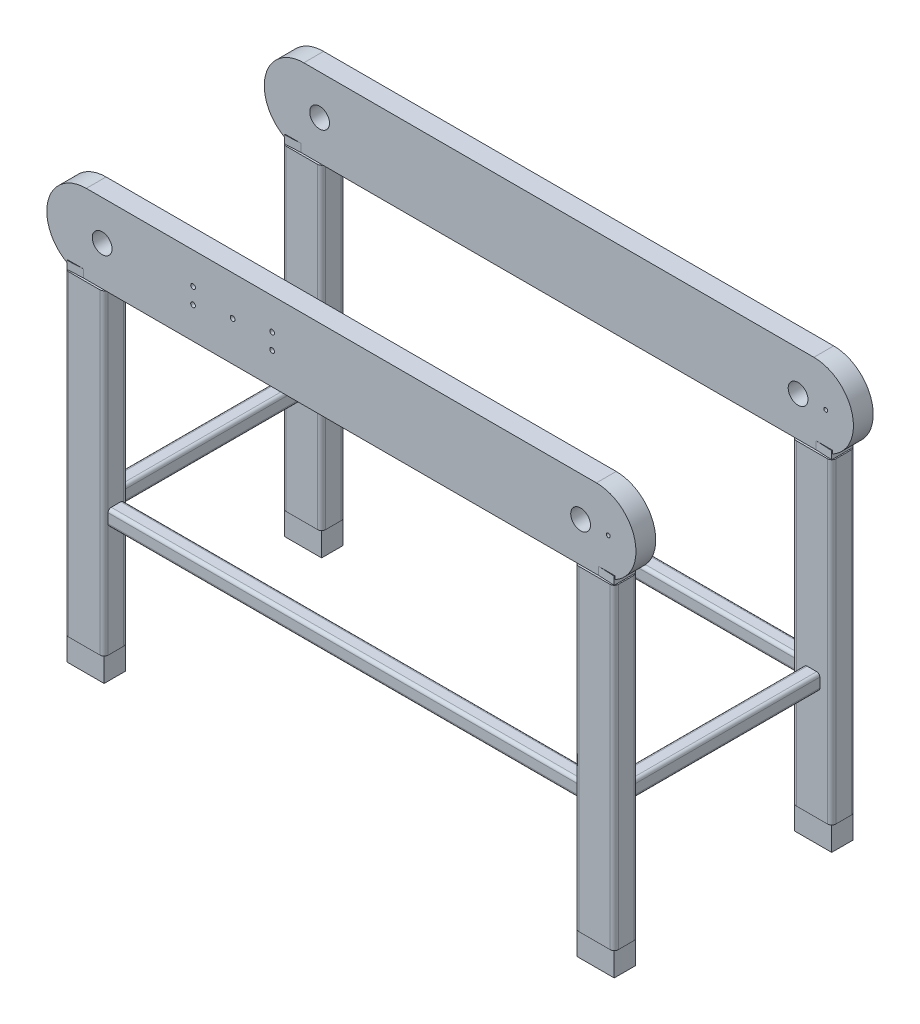
from build123d import *

# Parameters (mm, degrees)
BOSS_EXTRUDE3_START                          = 125
SKETCH4_R                                    = 12.5
BOSS_EXTRUDE3_DEPTH                          = 25
RECTANGULAR_TUBE_CONFIGURED_50_X_30_X_DEPTH  = 400
RECTANGULAR_TUBE_CONFIGURED_50_X_3_2_DEPTH   = 400
RECTANGULAR_TUBE_CONFIGURED_50_X_3_3_DEPTH   = 400
RECTANGULAR_TUBE_CONFIGURED_50_X_3_4_DEPTH   = 400
BOSS_EXTRUDE6_DEPTH                          = 10
LPATTERN2_COUNT                              = 2
LPATTERN2_PITCH                              = 275
BOSS_EXTRUDE7_DEPTH                          = 10
SQUARE_TUBE_CONFIGURED_20_X_20_X_2_3_DEPTH   = 595
SQUARE_TUBE_CONFIGURED_20_X_20_X_2_3_2_DEPTH = 595
SQUARE_TUBE_CONFIGURED_20_X_20_X_2_4_DEPTH   = 245
SQUARE_TUBE_CONFIGURED_20_X_20_X_2_4_2_DEPTH = 245
LPATTERN3_COUNT                              = 2
LPATTERN3_PITCH                              = 275
SKETCH117_R                                  = 3
CUT_EXTRUDE1_DEPTH                           = 10
SKETCH119_R                                  = 3
CUT_EXTRUDE2_DEPTH                           = 5
BOSS_EXTRUDE8_DEPTH                          = 30
BOSS_EXTRUDE8_2_DEPTH                        = 30
BOSS_EXTRUDE8_3_DEPTH                        = 30
BOSS_EXTRUDE8_4_DEPTH                        = 30
SKETCH120_R                                  = 2.5
CUT_EXTRUDE3_DEPTH                           = 464.5


with BuildPart() as part:
    # Sketch4 → Boss-Extrude3 (new body)
    with BuildSketch(Plane.XY.offset(BOSS_EXTRUDE3_START)):
        with BuildLine():
            Line((-29.379834074, 50), (615.620165926, 50))
            ThreePointArc((615.620165926, 50), (665.620165926, 0), (615.620165926, -50))
            Line((615.620165926, -50), (-29.379834074, -50))
            ThreePointArc((-29.379834074, -50), (-79.379834074, 0), (-29.379834074, 50))
        make_face()
        with Locations((-9.379834074, 0)):
            Circle(SKETCH4_R, mode=Mode.SUBTRACT)
        with Locations((595.620165926, 0)):
            Circle(SKETCH4_R, mode=Mode.SUBTRACT)
    extrude(amount=BOSS_EXTRUDE3_DEPTH)


with BuildPart() as body_2:
    # Mirror8: mirrored copy
    add(part.part.mirror(Plane.XY))


with BuildPart() as body_3:
    # Sketch13 → Rectangular tube - configured 50 X 30 X 2.6(1) (new body)
    with BuildSketch(Plane(origin=(-29.379834074, -50, -137.5), x_dir=(0, 0, -1), z_dir=(0, -1, 0))):
        with BuildLine():
            Line((-9.8, -25), (9.8, -25))
            ThreePointArc((9.8, -25), (13.476955262, -23.476955262), (15, -19.8))
            Line((15, -19.8), (15, 19.8))
            ThreePointArc((15, 19.8), (13.476955262, 23.476955262), (9.8, 25))
            Line((9.8, 25), (-9.8, 25))
            ThreePointArc((-9.8, 25), (-13.476955262, 23.476955262), (-15, 19.8))
            Line((-15, 19.8), (-15, -19.8))
            ThreePointArc((-15, -19.8), (-13.476955262, -23.476955262), (-9.8, -25))
        make_face()
        with BuildLine():
            Line((-9.8, -22.4), (9.8, -22.4))
            ThreePointArc((9.8, -22.4), (11.638477631, -21.638477631), (12.4, -19.8))
            Line((12.4, -19.8), (12.4, 19.8))
            ThreePointArc((12.4, 19.8), (11.638477631, 21.638477631), (9.8, 22.4))
            Line((9.8, 22.4), (-9.8, 22.4))
            ThreePointArc((-9.8, 22.4), (-11.638477631, 21.638477631), (-12.4, 19.8))
            Line((-12.4, 19.8), (-12.4, -19.8))
            ThreePointArc((-12.4, -19.8), (-11.638477631, -21.638477631), (-9.8, -22.4))
        make_face(mode=Mode.SUBTRACT)
    extrude(amount=RECTANGULAR_TUBE_CONFIGURED_50_X_30_X_DEPTH)


with BuildPart() as body_4:
    # Sketch13 on segment 2 (carried to segment 2) → Rectangular tube - configured 50 X 3 2 (new body)
    with BuildSketch(Plane(origin=(-29.379834074, -50, 137.5), x_dir=(0, 0, -1), z_dir=(0, -1, 0))):
        with BuildLine():
            Line((-9.8, -25), (9.8, -25))
            ThreePointArc((9.8, -25), (13.476955262, -23.476955262), (15, -19.8))
            Line((15, -19.8), (15, 19.8))
            ThreePointArc((15, 19.8), (13.476955262, 23.476955262), (9.8, 25))
            Line((9.8, 25), (-9.8, 25))
            ThreePointArc((-9.8, 25), (-13.476955262, 23.476955262), (-15, 19.8))
            Line((-15, 19.8), (-15, -19.8))
            ThreePointArc((-15, -19.8), (-13.476955262, -23.476955262), (-9.8, -25))
        make_face()
        with BuildLine():
            Line((-9.8, -22.4), (9.8, -22.4))
            ThreePointArc((9.8, -22.4), (11.638477631, -21.638477631), (12.4, -19.8))
            Line((12.4, -19.8), (12.4, 19.8))
            ThreePointArc((12.4, 19.8), (11.638477631, 21.638477631), (9.8, 22.4))
            Line((9.8, 22.4), (-9.8, 22.4))
            ThreePointArc((-9.8, 22.4), (-11.638477631, 21.638477631), (-12.4, 19.8))
            Line((-12.4, 19.8), (-12.4, -19.8))
            ThreePointArc((-12.4, -19.8), (-11.638477631, -21.638477631), (-9.8, -22.4))
        make_face(mode=Mode.SUBTRACT)
    extrude(amount=RECTANGULAR_TUBE_CONFIGURED_50_X_3_2_DEPTH)


with BuildPart() as body_5:
    # Sketch13 on segment 3 (carried to segment 3) → Rectangular tube - configured 50 X 3 3 (new body)
    with BuildSketch(Plane(origin=(615.620165926, -50, 137.5), x_dir=(0, 0, -1), z_dir=(0, -1, 0))):
        with BuildLine():
            Line((-9.8, -25), (9.8, -25))
            ThreePointArc((9.8, -25), (13.476955262, -23.476955262), (15, -19.8))
            Line((15, -19.8), (15, 19.8))
            ThreePointArc((15, 19.8), (13.476955262, 23.476955262), (9.8, 25))
            Line((9.8, 25), (-9.8, 25))
            ThreePointArc((-9.8, 25), (-13.476955262, 23.476955262), (-15, 19.8))
            Line((-15, 19.8), (-15, -19.8))
            ThreePointArc((-15, -19.8), (-13.476955262, -23.476955262), (-9.8, -25))
        make_face()
        with BuildLine():
            Line((-9.8, -22.4), (9.8, -22.4))
            ThreePointArc((9.8, -22.4), (11.638477631, -21.638477631), (12.4, -19.8))
            Line((12.4, -19.8), (12.4, 19.8))
            ThreePointArc((12.4, 19.8), (11.638477631, 21.638477631), (9.8, 22.4))
            Line((9.8, 22.4), (-9.8, 22.4))
            ThreePointArc((-9.8, 22.4), (-11.638477631, 21.638477631), (-12.4, 19.8))
            Line((-12.4, 19.8), (-12.4, -19.8))
            ThreePointArc((-12.4, -19.8), (-11.638477631, -21.638477631), (-9.8, -22.4))
        make_face(mode=Mode.SUBTRACT)
    extrude(amount=RECTANGULAR_TUBE_CONFIGURED_50_X_3_3_DEPTH)


with BuildPart() as body_6:
    # Sketch13 on segment 4 (carried to segment 4) → Rectangular tube - configured 50 X 3 4 (new body)
    with BuildSketch(Plane(origin=(615.620165926, -50, -137.5), x_dir=(0, 0, -1), z_dir=(0, -1, 0))):
        with BuildLine():
            Line((-9.8, -25), (9.8, -25))
            ThreePointArc((9.8, -25), (13.476955262, -23.476955262), (15, -19.8))
            Line((15, -19.8), (15, 19.8))
            ThreePointArc((15, 19.8), (13.476955262, 23.476955262), (9.8, 25))
            Line((9.8, 25), (-9.8, 25))
            ThreePointArc((-9.8, 25), (-13.476955262, 23.476955262), (-15, 19.8))
            Line((-15, 19.8), (-15, -19.8))
            ThreePointArc((-15, -19.8), (-13.476955262, -23.476955262), (-9.8, -25))
        make_face()
        with BuildLine():
            Line((-9.8, -22.4), (9.8, -22.4))
            ThreePointArc((9.8, -22.4), (11.638477631, -21.638477631), (12.4, -19.8))
            Line((12.4, -19.8), (12.4, 19.8))
            ThreePointArc((12.4, 19.8), (11.638477631, 21.638477631), (9.8, 22.4))
            Line((9.8, 22.4), (-9.8, 22.4))
            ThreePointArc((-9.8, 22.4), (-11.638477631, 21.638477631), (-12.4, 19.8))
            Line((-12.4, 19.8), (-12.4, -19.8))
            ThreePointArc((-12.4, -19.8), (-11.638477631, -21.638477631), (-9.8, -22.4))
        make_face(mode=Mode.SUBTRACT)
    extrude(amount=RECTANGULAR_TUBE_CONFIGURED_50_X_3_4_DEPTH)


with BuildPart() as body_7:
    # 3DSketch2 → Boss-Extrude6 (new body)
    with BuildSketch(Plane(origin=(639.097121189, -50, 150.976955262), x_dir=(-0.6599285573403962, 0, -0.7513283564505091), z_dir=(0, -1, 0))):
        Polygon((0, 0), (20.251237294, 17.787655287), (34.441606043, 0), (15.808662804, -16.366228222), align=None)
    boss_extrude6 = extrude(amount=-BOSS_EXTRUDE6_DEPTH)


with BuildPart() as lpattern2_1:
    # LPattern2: Boss-Extrude6 ×2
    with Locations(*[(0, 0, -i * LPATTERN2_PITCH) for i in range(1, LPATTERN2_COUNT)]):
        add(boss_extrude6)


with BuildPart() as body_9:
    # 3DSketch8 → Boss-Extrude7 (new body)
    with BuildSketch(Plane(origin=(-52.856789336, -50, -150.976955262), x_dir=(0.6515131239822392, 0, 0.7586373634872617), z_dir=(0, -1, 0))):
        Polygon((0, 0), (20.448243616, 17.560826449), (34.109782233, 0), (15.646966545, -15.855753097), align=None)
    boss_extrude7 = extrude(amount=-BOSS_EXTRUDE7_DEPTH)


with BuildPart() as body_10:
    # Sketch1 → Square tube - configured 20 X 20 X 2(3) (new body)
    with BuildSketch(Plane(origin=(-4.379834074, -300, -137.5), x_dir=(0, 0, -1), z_dir=(1, 0, 0))):
        with BuildLine():
            Line((-6, -10), (6, -10))
            ThreePointArc((6, -10), (8.828427125, -8.828427125), (10, -6))
            Line((10, -6), (10, 6))
            ThreePointArc((10, 6), (8.828427125, 8.828427125), (6, 10))
            Line((6, 10), (-6, 10))
            ThreePointArc((-6, 10), (-8.828427125, 8.828427125), (-10, 6))
            Line((-10, 6), (-10, -6))
            ThreePointArc((-10, -6), (-8.828427125, -8.828427125), (-6, -10))
        make_face()
        with BuildLine():
            Line((-6, -8), (6, -8))
            ThreePointArc((6, -8), (7.414213562, -7.414213562), (8, -6))
            Line((8, -6), (8, 6))
            ThreePointArc((8, 6), (7.414213562, 7.414213562), (6, 8))
            Line((6, 8), (-6, 8))
            ThreePointArc((-6, 8), (-7.414213562, 7.414213562), (-8, 6))
            Line((-8, 6), (-8, -6))
            ThreePointArc((-8, -6), (-7.414213562, -7.414213562), (-6, -8))
        make_face(mode=Mode.SUBTRACT)
    extrude(amount=SQUARE_TUBE_CONFIGURED_20_X_20_X_2_3_DEPTH)


with BuildPart() as body_11:
    # Sketch1 on segment 2 (carried to segment 2) → Square tube - configured 20 X 20 X 2_3 2 (new body)
    with BuildSketch(Plane(origin=(-4.379834074, -300, 137.5), x_dir=(0, 0, -1), z_dir=(1, 0, 0))):
        with BuildLine():
            Line((-6, -10), (6, -10))
            ThreePointArc((6, -10), (8.828427125, -8.828427125), (10, -6))
            Line((10, -6), (10, 6))
            ThreePointArc((10, 6), (8.828427125, 8.828427125), (6, 10))
            Line((6, 10), (-6, 10))
            ThreePointArc((-6, 10), (-8.828427125, 8.828427125), (-10, 6))
            Line((-10, 6), (-10, -6))
            ThreePointArc((-10, -6), (-8.828427125, -8.828427125), (-6, -10))
        make_face()
        with BuildLine():
            Line((-6, -8), (6, -8))
            ThreePointArc((6, -8), (7.414213562, -7.414213562), (8, -6))
            Line((8, -6), (8, 6))
            ThreePointArc((8, 6), (7.414213562, 7.414213562), (6, 8))
            Line((6, 8), (-6, 8))
            ThreePointArc((-6, 8), (-7.414213562, 7.414213562), (-8, 6))
            Line((-8, 6), (-8, -6))
            ThreePointArc((-8, -6), (-7.414213562, -7.414213562), (-6, -8))
        make_face(mode=Mode.SUBTRACT)
    extrude(amount=SQUARE_TUBE_CONFIGURED_20_X_20_X_2_3_2_DEPTH)


with BuildPart() as body_12:
    # Sketch116 → Square tube - configured 20 X 20 X 2(4) (new body)
    with BuildSketch(Plane(origin=(-29.379834074, -300, -122.5), x_dir=(1, 0, 0), z_dir=(0, 0, 1))):
        with BuildLine():
            Line((-6, -10), (6, -10))
            ThreePointArc((6, -10), (8.828427125, -8.828427125), (10, -6))
            Line((10, -6), (10, 6))
            ThreePointArc((10, 6), (8.828427125, 8.828427125), (6, 10))
            Line((6, 10), (-6, 10))
            ThreePointArc((-6, 10), (-8.828427125, 8.828427125), (-10, 6))
            Line((-10, 6), (-10, -6))
            ThreePointArc((-10, -6), (-8.828427125, -8.828427125), (-6, -10))
        make_face()
        with BuildLine():
            Line((-6, -8), (6, -8))
            ThreePointArc((6, -8), (7.414213562, -7.414213562), (8, -6))
            Line((8, -6), (8, 6))
            ThreePointArc((8, 6), (7.414213562, 7.414213562), (6, 8))
            Line((6, 8), (-6, 8))
            ThreePointArc((-6, 8), (-7.414213562, 7.414213562), (-8, 6))
            Line((-8, 6), (-8, -6))
            ThreePointArc((-8, -6), (-7.414213562, -7.414213562), (-6, -8))
        make_face(mode=Mode.SUBTRACT)
    extrude(amount=SQUARE_TUBE_CONFIGURED_20_X_20_X_2_4_DEPTH)


with BuildPart() as body_13:
    # Sketch116 on segment 2 (carried to segment 2) → Square tube - configured 20 X 20 X 2_4 2 (new body)
    with BuildSketch(Plane(origin=(615.620165926, -300, -122.5), x_dir=(1, 0, 0), z_dir=(0, 0, 1))):
        with BuildLine():
            Line((-6, -10), (6, -10))
            ThreePointArc((6, -10), (8.828427125, -8.828427125), (10, -6))
            Line((10, -6), (10, 6))
            ThreePointArc((10, 6), (8.828427125, 8.828427125), (6, 10))
            Line((6, 10), (-6, 10))
            ThreePointArc((-6, 10), (-8.828427125, 8.828427125), (-10, 6))
            Line((-10, 6), (-10, -6))
            ThreePointArc((-10, -6), (-8.828427125, -8.828427125), (-6, -10))
        make_face()
        with BuildLine():
            Line((-6, -8), (6, -8))
            ThreePointArc((6, -8), (7.414213562, -7.414213562), (8, -6))
            Line((8, -6), (8, 6))
            ThreePointArc((8, 6), (7.414213562, 7.414213562), (6, 8))
            Line((6, 8), (-6, 8))
            ThreePointArc((-6, 8), (-7.414213562, 7.414213562), (-8, 6))
            Line((-8, 6), (-8, -6))
            ThreePointArc((-8, -6), (-7.414213562, -7.414213562), (-6, -8))
        make_face(mode=Mode.SUBTRACT)
    extrude(amount=SQUARE_TUBE_CONFIGURED_20_X_20_X_2_4_2_DEPTH)


with BuildPart() as lpattern3_1:
    # LPattern3: Boss-Extrude7 ×2
    with Locations(*[(0, 0, i * LPATTERN3_PITCH) for i in range(1, LPATTERN3_COUNT)]):
        add(boss_extrude7)


with BuildPart() as body_2_1:
    add(body_2.part)

    # Combine1: union body 9, LPattern2_1
    add(body_9.part)
    add(lpattern2_1.part)

    # Sketch119 → Cut-Extrude2 (cut)
    with BuildSketch(Plane(origin=(0, 0, -150), x_dir=(-1, 0, 0), z_dir=(0, 0, -1))):
        with Locations((-155.620165926, 0.160473336)):
            Circle(SKETCH119_R)
        with Locations((-205.620165926, 10.160473336)):
            Circle(SKETCH119_R)
        with Locations((-205.620165926, -9.839526664)):
            Circle(SKETCH119_R)
        with Locations((-105.620165926, 10.160473336)):
            Circle(SKETCH119_R)
        with Locations((-105.620165926, -9.839526664)):
            Circle(SKETCH119_R)
    extrude(amount=-CUT_EXTRUDE2_DEPTH, mode=Mode.SUBTRACT)


with BuildPart() as part_1:
    add(part.part)

    # Combine2: union LPattern3_1, body 7
    add(lpattern3_1.part)
    add(body_7.part)

    # Sketch117 → Cut-Extrude1 (cut)
    with BuildSketch(Plane.XY.offset(150)):
        with BuildLine():
            ThreePointArc((208.620165926, 10), (205.620165926, 13), (202.620165926, 10))
            Line((202.620165926, 10), (205.620165926, 10))
            Line((205.620165926, 10), (205.620165926, 7))
            ThreePointArc((205.620165926, 7), (207.74148627, 7.878679656), (208.620165926, 10))
        make_face()
        with BuildLine():
            Line((205.620165926, 10), (202.620165926, 10))
            ThreePointArc((202.620165926, 10), (203.498845583, 7.878679656), (205.620165926, 7))
            Line((205.620165926, 7), (205.620165926, 10))
        make_face()
        with Locations((105.620165926, 10)):
            Circle(SKETCH117_R)
        with Locations((105.620165926, -10)):
            Circle(SKETCH117_R)
        with Locations((155.620165926, 0)):
            Circle(SKETCH117_R)
        with Locations((205.620165926, -10)):
            Circle(SKETCH117_R)
    extrude(amount=-CUT_EXTRUDE1_DEPTH, mode=Mode.SUBTRACT)


with BuildPart() as body_11_2:
    # 3DSketch12 → Boss-Extrude8 (new body)
    with BuildSketch(Plane(origin=(-52.856789336, -450, 124.023044738), x_dir=(0.9292994530677143, 0, -0.36932712671566276), z_dir=(0, -1, 0))):
        Polygon((0, 0), (-9.954810328, 25.048254308), (33.679433042, 42.38960717), (43.63424337, 17.341352862), align=None)
    extrude(amount=BOSS_EXTRUDE8_DEPTH)


with BuildPart() as body_12_2:
    # 3DSketch12 → Boss-Extrude8 2 (new body)
    with BuildSketch(Plane(origin=(-52.856789336, -450, 124.023044738), x_dir=(0.9292994530677143, 0, -0.36932712671566276), z_dir=(0, -1, 0))):
        Polygon((643.032390598, 255.557349594), (633.077580271, 280.605603902), (589.443336901, 263.26425104), (599.398147229, 238.215996732), align=None)
    extrude(amount=BOSS_EXTRUDE8_2_DEPTH)


with BuildPart() as body_13_2:
    # 3DSketch12 → Boss-Extrude8 3 (new body)
    with BuildSketch(Plane(origin=(-52.856789336, -450, 124.023044738), x_dir=(0.9292994530677143, 0, -0.36932712671566276), z_dir=(0, -1, 0))):
        Polygon((744.597350445, 0), (734.642540117, 25.048254308), (691.008296748, 7.706901446), (700.963107075, -17.341352862), align=None)
    extrude(amount=BOSS_EXTRUDE8_3_DEPTH)


with BuildPart() as body_14:
    # 3DSketch12 → Boss-Extrude8 4 (new body)
    with BuildSketch(Plane(origin=(-52.856789336, -450, 124.023044738), x_dir=(0.9292994530677143, 0, -0.36932712671566276), z_dir=(0, -1, 0))):
        Polygon((145.199203216, -238.215996732), (135.244392889, -213.167742423), (91.610149519, -230.509095285), (101.564959847, -255.557349594), align=None)
    extrude(amount=BOSS_EXTRUDE8_4_DEPTH)


with BuildPart() as cut_extrude3_tool:
    # Sketch120 → Cut-Extrude3 (new, symmetric)
    with BuildSketch(Plane(origin=(0, 0, 125), x_dir=(-1, 0, 0), z_dir=(0, 0, -1))):
        with Locations(Location((-630.620165926, 0, 0), (0, 0, 180))):
            Circle(SKETCH120_R)
    extrude(amount=CUT_EXTRUDE3_DEPTH, both=True)


with BuildPart() as part_2:
    add(part_1.part)

    # Cut-Extrude3: cut by cut_extrude3_tool
    add(cut_extrude3_tool.part, mode=Mode.SUBTRACT)


with BuildPart() as body_2_2:
    add(body_2_1.part)

    # Cut-Extrude3: cut by cut_extrude3_tool
    add(cut_extrude3_tool.part, mode=Mode.SUBTRACT)


solid = Compound([body_3.part, body_4.part, body_5.part, body_6.part, body_10.part, body_11.part, body_12.part, body_13.part, body_11_2.part, body_12_2.part, body_13_2.part, body_14.part, part_2.part, body_2_2.part])
